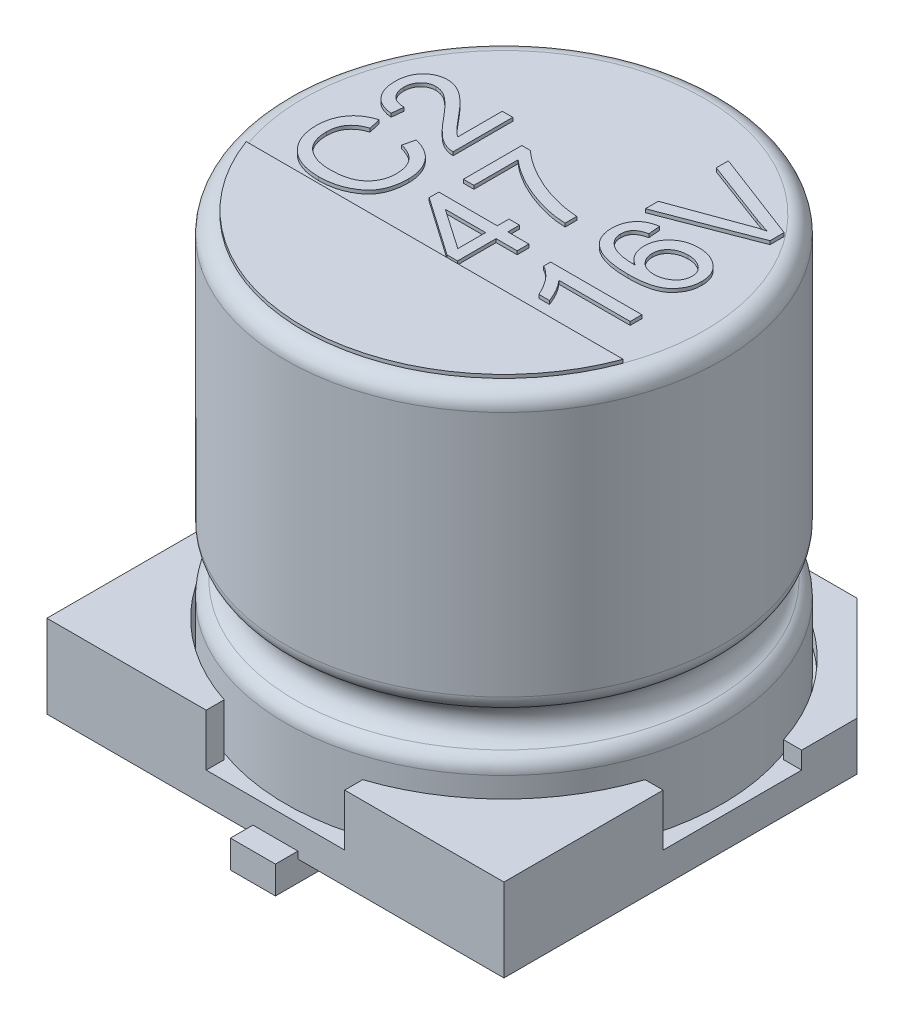
from build123d import *

# Parameters (mm, degrees)
ESQUISSE1_W               = 6.6
ESQUISSE1_H               = 6.6
BOSS_EXTRU_1_DEPTH        = 1.2
ESQUISSE2_R               = 3.2
ESQUISSE2_W               = 6.6
ESQUISSE2_H               = 2
ESQUISSE2_W_2             = 2
ESQUISSE2_H_2             = 6.6
ENL_V_MAT_EXTRU_1_DEPTH   = 0.75
ESQUISSE3_W               = 6.6
ESQUISSE3_H               = 3.3
ENL_V_MAT_EXTRU_2_DEPTH   = 0.5
CHANFREIN1_SIZE           = 1.5
ESQUISSE5_W               = 0.65
ESQUISSE5_H               = 0.65
BOSS_EXTRU_2_DEPTH        = 0.3
BOSS_EXTRU_2_DEPTH_BACK   = 0.1
BOSS_EXTRU_2_2_DEPTH      = 0.3
BOSS_EXTRU_2_2_DEPTH_BACK = 0.1
ESQUISSE6_R               = 0.5
BOSS_EXTRU_3_DEPTH        = 0.3
BOSS_EXTRU_4_DEPTH        = 0.05
BOSS_EXTRU_4_2_DEPTH      = 0.05
BOSS_EXTRU_4_3_DEPTH      = 0.05
BOSS_EXTRU_4_4_DEPTH      = 0.05
BOSS_EXTRU_4_5_DEPTH      = 0.05
BOSS_EXTRU_4_6_DEPTH      = 0.05
BOSS_EXTRU_4_7_DEPTH      = 0.05
BOSS_EXTRU_4_8_DEPTH      = 0.05


with BuildPart() as part:
    # Esquisse1 → Boss.-Extru.1 (new body)
    with BuildSketch(Plane(origin=(0, 0, 0), x_dir=(1, 0, 0), z_dir=(0, 1, 0))):
        Rectangle(ESQUISSE1_W, ESQUISSE1_H)
    extrude(amount=BOSS_EXTRU_1_DEPTH)

    # Esquisse2 → Enlèv. mat.-Extru.1 (cut)
    with BuildSketch(Plane(origin=(0, 1.2, 0), x_dir=(1, 0, 0), z_dir=(0, 1, 0))):
        Circle(ESQUISSE2_R)
        Rectangle(ESQUISSE2_W, ESQUISSE2_H)
        Rectangle(ESQUISSE2_W_2, ESQUISSE2_H_2)
    extrude(amount=-ENL_V_MAT_EXTRU_1_DEPTH, mode=Mode.SUBTRACT)

    # Esquisse3 → Enlèv. mat.-Extru.2 (cut)
    with BuildSketch(Plane(origin=(0, 1.2, 0), x_dir=(1, 0, 0), z_dir=(0, 1, 0))):
        with Locations((0, 1.65)):
            Rectangle(ESQUISSE3_W, ESQUISSE3_H)
    extrude(amount=-ENL_V_MAT_EXTRU_2_DEPTH, mode=Mode.SUBTRACT)

    # Chanfrein1
    chanfrein1_edges = [part.edges().sort_by_distance(p)[0] for p in [
        (3.3, 0.35, -3.3),
        (-3.3, 0.35, -3.3),
    ]]
    chamfer(chanfrein1_edges, length=CHANFREIN1_SIZE)

    # Esquisse6 → Boss.-Extru.3 (add)
    with BuildSketch(Plane.XZ):
        with Locations(Location((-2, 2, 0), (0, 0, 270))):  # turned: the seam where the file's is
            Circle(ESQUISSE6_R)
        with Locations(Location((2, 2, 0), (0, 0, 270))):  # turned: the seam where the file's is
            Circle(ESQUISSE6_R)
        with Locations(Location((2, -2, 0), (0, 0, 270))):  # turned: the seam where the file's is
            Circle(ESQUISSE6_R)
        with Locations(Location((-2, -2, 0), (0, 0, 270))):  # turned: the seam where the file's is
            Circle(ESQUISSE6_R)
    extrude(amount=BOSS_EXTRU_3_DEPTH)


with BuildPart() as body_2:
    # Esquisse4 → Révolution1 (revolve)
    with BuildSketch(Plane(origin=(0, 0, 0), x_dir=(0, 0, -1), z_dir=(1, 0, 0)), mode=Mode.PRIVATE) as r_volution1_sk:
        with BuildLine():
            Line((0, 6.25), (-2.9, 6.25))
            ThreePointArc((-2.9, 6.25), (-3.076776695, 6.176776695), (-3.15, 6))
            Line((-3.15, 6), (-3.15, 2.439897949))
            ThreePointArc((-3.15, 2.439897949), (-3.113200716, 2.309339707), (-3.013636364, 2.217217063))
            ThreePointArc((-3.013636364, 2.217217063), (-2.85, 1.95), (-3.013636364, 1.682782937))
            ThreePointArc((-3.013636364, 1.682782937), (-3.113200716, 1.590660293), (-3.15, 1.460102051))
            Line((-3.15, 1.460102051), (-3.15, 0.45))
            Line((-3.15, 0.45), (0, 0.45))
            Line((0, 0.45), (0, 6.25))
        make_face()
    revolve(r_volution1_sk.sketch.rotate(Axis((0, 0.45, 0), (0, 1, 0)), 180), axis=Axis((0, 0.45, 0), (0, 1, 0)))  # turned: the seam where the file's is


with BuildPart() as body_3:
    # Esquisse5 → Boss.-Extru.2 (new body, two sides)
    with BuildSketch(Plane.XZ) as boss_extru_2_sk:
        with Locations((0, 3.3)):
            Rectangle(ESQUISSE5_W, ESQUISSE5_H)
    extrude(amount=BOSS_EXTRU_2_DEPTH)
    extrude(boss_extru_2_sk.sketch, amount=-BOSS_EXTRU_2_DEPTH_BACK)


with BuildPart() as body_4:
    # Esquisse5 → Boss.-Extru.2 2 (new body, two sides)
    with BuildSketch(Plane.XZ) as boss_extru_2_2_sk:
        with Locations((0, -3.3)):
            Rectangle(ESQUISSE5_W, ESQUISSE5_H)
    extrude(amount=BOSS_EXTRU_2_2_DEPTH)
    extrude(boss_extru_2_2_sk.sketch, amount=-BOSS_EXTRU_2_2_DEPTH_BACK)


with BuildPart() as body_5:
    # Esquisse7 → Boss.-Extru.4 (new body)
    with BuildSketch(Plane(origin=(0, 6.25, 0), x_dir=(1, 0, 0), z_dir=(0, 1, 0))):
        with BuildLine():
            Line((-2.722131518, -1), (2.722131518, -1))
            ThreePointArc((2.722131518, -1), (0, -2.9), (-2.722131518, -1))
        make_face()
    extrude(amount=BOSS_EXTRU_4_DEPTH)


with BuildPart() as body_6:
    # Esquisse7 → Boss.-Extru.4 2 (new body)
    with BuildSketch(Plane(origin=(0, 6.25, 0), x_dir=(1, 0, 0), z_dir=(0, 1, 0))):
        Polygon((0.296103896, -0.071428571), (0.296103896, -0.24025974), (0.6, -0.24025974), (0.6, -0.409090909), (0.296103896, -0.409090909), (0.296103896, -0.966233766), (0.144155844, -0.966233766), (-0.7, -0.379017857), (-0.7, -0.24025974), (0.144155844, -0.24025974), (0.144155844, -0.071428571), align=None)
        Polygon((0.144155844, -0.409090909), (-0.432508117, -0.409090909), (-0.432508117, -0.412520292), (0.144155844, -0.810064935), align=None, mode=Mode.SUBTRACT)
    extrude(amount=BOSS_EXTRU_4_2_DEPTH)


with BuildPart() as body_7:
    # Esquisse7 → Boss.-Extru.4 3 (new body)
    with BuildSketch(Plane(origin=(0, 6.25, 0), x_dir=(1, 0, 0), z_dir=(0, 1, 0))):
        with BuildLine():
            add(Edge.make_bspline(
                [(-0.561769481, 0.941558442), (-0.543990179, 0.925717685), (-0.508027109, 0.893675804), (-0.450586487, 0.848641711), (-0.3904709, 0.80453927), (-0.326676072, 0.762899908), (-0.260252054, 0.721970855), (-0.19025817, 0.683445144), (-0.117295293, 0.646115762), (-0.041643658, 0.610664543), (0.036098502, 0.578196899), (0.11472146, 0.548637502), (0.194253592, 0.523543832), (0.274149315, 0.50138235), (0.354781461, 0.483647136), (0.435863592, 0.46891175), (0.517682436, 0.458379626), (0.572543391, 0.454093271), (0.6, 0.451948052)],
                knots=[0, 0, 0, 0, 0.890443169, 1.8011434, 2.72871408, 3.67830878, 4.649628621, 5.64630914, 6.665648346, 7.714738694, 8.77023317, 9.816117091, 10.855215011, 11.888472104, 12.916223604, 13.941999776, 14.970019627, 16, 16, 16, 16], degree=3))
            Line((0.6, 0.451948052), (0.6, 0.283116883))
            add(Edge.make_bspline(
                [(0.6, 0.283116883), (0.577563575, 0.284043261), (0.531991638, 0.285924881), (0.462851153, 0.292875252), (0.392095355, 0.303794478), (0.319788097, 0.318428905), (0.245841613, 0.336366822), (0.170220452, 0.35803723), (0.093079903, 0.383812161), (0.014824341, 0.412421512), (-0.06269314, 0.44439909), (-0.138070487, 0.478962459), (-0.210847697, 0.515514293), (-0.280520376, 0.554995133), (-0.34760432, 0.59655633), (-0.411639883, 0.640745749), (-0.473239776, 0.686727654), (-0.51191236, 0.719836812), (-0.531168831, 0.736323052)],
                knots=[0, 0, 0, 0, 0.869045849, 1.765169938, 2.687948117, 3.639137891, 4.619848113, 5.632498604, 6.682982998, 7.767344363, 8.85702895, 9.927714978, 10.976477627, 12.008263417, 13.026390201, 14.029951021, 15.01904175, 16, 16, 16, 16], degree=3))
            Line((-0.531168831, 0.736323052), (-0.531168831, 0.097402597))
            Line((-0.531168831, 0.097402597), (-0.683116883, 0.097402597))
            Line((-0.683116883, 0.097402597), (-0.683116883, 0.941558442))
            Line((-0.683116883, 0.941558442), (-0.561769481, 0.941558442))
        make_face()
    extrude(amount=BOSS_EXTRU_4_3_DEPTH)


with BuildPart() as body_8:
    # Esquisse7 → Boss.-Extru.4 4 (new body)
    with BuildSketch(Plane(origin=(0, 6.25, 0), x_dir=(1, 0, 0), z_dir=(0, 1, 0))):
        with BuildLine():
            Line((2.3, -0.307792208), (2.3, -0.476623377))
            Line((2.3, -0.476623377), (1.27012987, -0.476623377))
            add(Edge.make_bspline(
                [(1.27012987, -0.476623377), (1.279223462, -0.486984406), (1.297670325, -0.508002338), (1.323418107, -0.541939461), (1.348324339, -0.578158837), (1.372037178, -0.617024985), (1.39472956, -0.658496452), (1.416257396, -0.702559652), (1.436916947, -0.748996188), (1.449463122, -0.781083079), (1.455844156, -0.797402597)],
                knots=[0, 0, 0, 0, 0.887204464, 1.799744156, 2.740245044, 3.715929421, 4.729246756, 5.78238396, 6.872111789, 8, 8, 8, 8], degree=3))
            Line((1.455844156, -0.797402597), (1.303896104, -0.797402597))
            add(Edge.make_bspline(
                [(1.303896104, -0.797402597), (1.293102344, -0.774483614), (1.272072929, -0.729830701), (1.236626461, -0.66705158), (1.199399203, -0.609831301), (1.16045468, -0.558087831), (1.119141498, -0.512270563), (1.076102522, -0.471980489), (1.031133268, -0.437074324), (0.998988334, -0.418340614), (0.983116883, -0.409090909)],
                knots=[0, 0, 0, 0, 1.186218497, 2.3111021, 3.37345738, 4.381680583, 5.341076965, 6.258983301, 7.14037897, 8, 8, 8, 8], degree=3))
            Line((0.983116883, -0.409090909), (0.983116883, -0.307792208))
            Line((0.983116883, -0.307792208), (2.3, -0.307792208))
        make_face()
    extrude(amount=BOSS_EXTRU_4_4_DEPTH)


with BuildPart() as body_9:
    # Esquisse7 → Boss.-Extru.4 5 (new body)
    with BuildSketch(Plane(origin=(0, 6.25, 0), x_dir=(1, 0, 0), z_dir=(0, 1, 0))):
        with BuildLine():
            add(Edge.make_bspline(
                [(1.627049513, 0.266233766), (1.613450204, 0.275238165), (1.586906324, 0.292813447), (1.551847818, 0.323932831), (1.52224805, 0.358062815), (1.497757448, 0.394853213), (1.478733011, 0.434622693), (1.465738061, 0.47733157), (1.457178022, 0.522656734), (1.456294986, 0.5539099), (1.455844156, 0.569866071)],
                knots=[0, 0, 0, 0, 1.069954415, 2.088395883, 3.066632478, 4.029065089, 4.982046927, 5.949919737, 6.953340264, 8, 8, 8, 8], degree=3))
            add(Edge.make_bspline(
                [(1.455844156, 0.569866071), (1.456191805, 0.582548179), (1.456878439, 0.607596362), (1.462545816, 0.64439928), (1.471850024, 0.679631672), (1.484485531, 0.713546338), (1.501385133, 0.7457272), (1.521383712, 0.776893214), (1.545647627, 0.806087597), (1.57293232, 0.833726618), (1.603149516, 0.858887064), (1.63558394, 0.88126992), (1.670435777, 0.899630894), (1.70699582, 0.915123616), (1.745722852, 0.927004517), (1.786547903, 0.935275404), (1.829318218, 0.940838077), (1.858558723, 0.941315506), (1.8734375, 0.941558442)],
                knots=[0, 0, 0, 0, 0.975125205, 1.925950693, 2.856152245, 3.774449697, 4.70315003, 5.646803566, 6.617626571, 7.617215937, 8.630442275, 9.637872749, 10.642483832, 11.65496491, 12.688309326, 13.752171127, 14.856211817, 16, 16, 16, 16], degree=3))
            add(Edge.make_bspline(
                [(1.8734375, 0.941558442), (1.888580343, 0.941317494), (1.918347182, 0.940843855), (1.961983437, 0.935238168), (2.004065218, 0.926985596), (2.04426656, 0.91475994), (2.082960891, 0.899469991), (2.119576045, 0.880323032), (2.154744008, 0.858075663), (2.187621145, 0.832380443), (2.218017881, 0.804115367), (2.244524958, 0.773169631), (2.26683893, 0.739924589), (2.285202716, 0.704550145), (2.299579764, 0.666870265), (2.309430036, 0.626812278), (2.315698497, 0.584571905), (2.316482257, 0.55564374), (2.316883117, 0.540848214)],
                knots=[0, 0, 0, 0, 1.085548404, 2.133902048, 3.150719742, 4.158438961, 5.143478499, 6.130857801, 7.117733313, 8.124563847, 9.119649328, 10.090449915, 11.040371519, 11.985443394, 12.943683995, 13.925811242, 14.939140701, 16, 16, 16, 16], degree=3))
            add(Edge.make_bspline(
                [(2.316883117, 0.540848214), (2.316485003, 0.525789733), (2.315699126, 0.496064278), (2.30922735, 0.45227623), (2.298467941, 0.410260062), (2.283175096, 0.369999989), (2.263930883, 0.331398768), (2.240229667, 0.294431855), (2.212090634, 0.25937232), (2.185526962, 0.231697854), (2.16173043, 0.210909807), (2.141984459, 0.196313685), (2.12071524, 0.182321071), (2.097548676, 0.169925454), (2.072879154, 0.158124335), (2.046428775, 0.147771295), (2.018546469, 0.137838126), (1.988771702, 0.129565645), (1.957480451, 0.121857064), (1.924464164, 0.115322522), (1.889799343, 0.10974132), (1.853435335, 0.105427189), (1.815463748, 0.101534382), (1.775761166, 0.099407309), (1.734430917, 0.09766443), (1.70627918, 0.09749094), (1.691943994, 0.097402597)],
                knots=[0, 0, 0, 0, 1.247779403, 2.463117631, 3.659976664, 4.836419457, 6.026221779, 7.229279442, 8.468942427, 9.747322861, 10.403533791, 11.085784176, 11.78126166, 12.511907243, 13.26182283, 14.046870347, 14.865219006, 15.714252586, 16.607026578, 17.536193268, 18.503241106, 19.516724355, 20.571286828, 21.666600567, 22.811806305, 24, 24, 24, 24], degree=3))
            add(Edge.make_bspline(
                [(1.691943994, 0.097402597), (1.66405944, 0.097732004), (1.610078492, 0.098369693), (1.53179155, 0.103971256), (1.45884114, 0.113044828), (1.391205321, 0.125820084), (1.328908012, 0.142369357), (1.271919877, 0.16260206), (1.220163171, 0.186578768), (1.173754642, 0.214256842), (1.132735067, 0.245565842), (1.097145189, 0.280237509), (1.066919268, 0.318271077), (1.042563218, 0.359827163), (1.02338332, 0.404577389), (1.009730122, 0.452607049), (1.001342979, 0.503973819), (1.000455589, 0.53932045), (1, 0.557467532)],
                knots=[0, 0, 0, 0, 1.424582619, 2.757810733, 4.007769843, 5.178820556, 6.271924257, 7.297969076, 8.264779121, 9.181696118, 10.053356541, 10.895296698, 11.714155951, 12.52784682, 13.349044585, 14.195146158, 15.073381762, 16, 16, 16, 16], degree=3))
            add(Edge.make_bspline(
                [(1, 0.557467532), (1.000266189, 0.569347725), (1.000788053, 0.592638937), (1.004513002, 0.626879674), (1.010823326, 0.659713581), (1.019796421, 0.691242231), (1.031438305, 0.721314076), (1.045468679, 0.750058478), (1.062151749, 0.777202626), (1.081137312, 0.802951217), (1.10276139, 0.826674161), (1.1269229, 0.848246212), (1.153717516, 0.867207906), (1.182816476, 0.883930992), (1.2145108, 0.897931697), (1.248615786, 0.909424797), (1.285095392, 0.918837371), (1.310447816, 0.922699565), (1.323417208, 0.924675325)],
                knots=[0, 0, 0, 0, 1.05367056, 2.065729412, 3.050830916, 4.016126385, 4.969213069, 5.907536784, 6.849258065, 7.791463712, 8.741097404, 9.691307467, 10.658743283, 11.647450802, 12.663499054, 13.726567437, 14.836993312, 16, 16, 16, 16], degree=3))
            Line((1.323417208, 0.924675325), (1.337662338, 0.755844156))
            add(Edge.make_bspline(
                [(1.337662338, 0.755844156), (1.321728395, 0.75208586), (1.291447841, 0.744943667), (1.249723652, 0.728902171), (1.214342308, 0.708544848), (1.185174599, 0.684021814), (1.162541528, 0.655279008), (1.14637255, 0.622526032), (1.136698364, 0.585712537), (1.135622605, 0.559813809), (1.135064935, 0.546387987)],
                knots=[0, 0, 0, 0, 1.226492651, 2.330802743, 3.33829511, 4.273637758, 5.170477757, 6.060897429, 6.994775133, 8, 8, 8, 8], degree=3))
            add(Edge.make_bspline(
                [(1.135064935, 0.546387987), (1.135418359, 0.536865112), (1.13612146, 0.517920305), (1.141813944, 0.490115874), (1.15120395, 0.463353983), (1.164247094, 0.437644759), (1.181017926, 0.412855033), (1.201917031, 0.389479109), (1.225918202, 0.366662204), (1.253763855, 0.345234113), (1.285645474, 0.325567517), (1.321890842, 0.308436717), (1.362583263, 0.294435138), (1.40723256, 0.282445887), (1.456249779, 0.27378698), (1.509334201, 0.26718345), (1.566755969, 0.26323262), (1.606466954, 0.262776826), (1.627049513, 0.262540584)],
                knots=[0, 0, 0, 0, 0.724409215, 1.441139678, 2.150297782, 2.877700373, 3.629574527, 4.421695389, 5.259767472, 6.14740045, 7.091057935, 8.106037173, 9.192047824, 10.362655148, 11.621681866, 12.977431459, 14.433375649, 16, 16, 16, 16], degree=3))
            Line((1.627049513, 0.262540584), (1.627049513, 0.266233766))
        make_face()
        with BuildLine():
            add(Edge.make_bspline(
                [(2.181818182, 0.536099838), (2.181568318, 0.544730718), (2.181078587, 0.561647203), (2.177124181, 0.586405497), (2.170111881, 0.609693653), (2.160894294, 0.631944567), (2.148641556, 0.652804154), (2.133757323, 0.672448191), (2.116205223, 0.690740401), (2.096179435, 0.707446087), (2.074354581, 0.722675103), (2.051171698, 0.736142616), (2.02680406, 0.74752572), (2.001378748, 0.756771669), (1.974821002, 0.763969329), (1.947084994, 0.768811814), (1.918276627, 0.77216642), (1.898684144, 0.772538422), (1.888737825, 0.772727273)],
                knots=[0, 0, 0, 0, 0.985621802, 1.931814126, 2.853484768, 3.758252722, 4.676468835, 5.608588604, 6.5676484, 7.56562942, 8.582686171, 9.604295749, 10.624324039, 11.65066286, 12.691060434, 13.762839569, 14.864283136, 16, 16, 16, 16], degree=3))
            add(Edge.make_bspline(
                [(1.888737825, 0.772727273), (1.878791822, 0.772538292), (1.859287392, 0.772167695), (1.830818773, 0.76886745), (1.803625762, 0.763924886), (1.77774465, 0.75681719), (1.753100396, 0.747564027), (1.729761047, 0.73619713), (1.707854683, 0.722641789), (1.687250682, 0.70743414), (1.668584593, 0.690451128), (1.652408352, 0.671792765), (1.638410137, 0.651947387), (1.627512427, 0.63030834), (1.618191522, 0.60759186), (1.612402747, 0.583107837), (1.608551277, 0.55741421), (1.608048678, 0.539808054), (1.607792208, 0.530823864)],
                knots=[0, 0, 0, 0, 1.146383952, 2.248095505, 3.300025281, 4.330631945, 5.338088421, 6.331106039, 7.318778256, 8.304262475, 9.280208679, 10.221574778, 11.146861143, 12.071925297, 13.009516616, 13.970978403, 14.964616916, 16, 16, 16, 16], degree=3))
            add(Edge.make_bspline(
                [(1.607792208, 0.530823864), (1.607939363, 0.522541124), (1.608230522, 0.506152986), (1.612236929, 0.482077137), (1.617844731, 0.458763298), (1.626262155, 0.436375771), (1.636613389, 0.414751193), (1.649943308, 0.394347961), (1.664828806, 0.374353159), (1.682526243, 0.355882187), (1.701818666, 0.338759636), (1.722905284, 0.323875968), (1.745387123, 0.311119324), (1.769547778, 0.300788247), (1.795238644, 0.292988165), (1.822303769, 0.287105465), (1.850836163, 0.283644735), (1.870350413, 0.283295088), (1.880296266, 0.283116883)],
                knots=[0, 0, 0, 0, 0.964721787, 1.908788045, 2.83888565, 3.756980023, 4.692487839, 5.628332754, 6.594252615, 7.595238226, 8.60516442, 9.598082325, 10.599015417, 11.614185319, 12.655278625, 13.72520881, 14.840604126, 16, 16, 16, 16], degree=3))
            add(Edge.make_bspline(
                [(1.880296266, 0.283116883), (1.890507691, 0.283286935), (1.910638719, 0.283622179), (1.940255727, 0.287255443), (1.968804316, 0.292626469), (1.99617096, 0.300626163), (2.022286204, 0.310915399), (2.047226077, 0.323430039), (2.071143302, 0.337956198), (2.093546616, 0.354775367), (2.114389341, 0.37294797), (2.132380715, 0.392825333), (2.147634985, 0.413865872), (2.160026551, 0.436123402), (2.169953686, 0.459427418), (2.176741364, 0.484003962), (2.181161479, 0.50964767), (2.181597232, 0.527199926), (2.181818182, 0.536099838)],
                knots=[0, 0, 0, 0, 1.117888879, 2.203830858, 3.263487087, 4.296727522, 5.321539455, 6.333737417, 7.349594489, 8.38207154, 9.398658853, 10.373700902, 11.311944705, 12.238999299, 13.158417895, 14.079197511, 15.026052622, 16, 16, 16, 16], degree=3))
        make_face(mode=Mode.SUBTRACT)
    extrude(amount=BOSS_EXTRU_4_5_DEPTH)


with BuildPart() as body_10:
    # Esquisse7 → Boss.-Extru.4 6 (new body)
    with BuildSketch(Plane(origin=(0, 6.25, 0), x_dir=(1, 0, 0), z_dir=(0, 1, 0))):
        with BuildLine():
            Line((1, 2.241558442), (2.3, 1.746672078))
            Line((2.3, 1.746672078), (2.3, 1.543019481))
            Line((2.3, 1.543019481), (1, 1.042857143))
            Line((1, 1.042857143), (1, 1.229362825))
            Line((1, 1.229362825), (1.943871753, 1.57362013))
            add(Edge.make_bspline(
                [(1.943871753, 1.57362013), (1.959566765, 1.579978572), (1.991939898, 1.593093737), (2.042890769, 1.611101638), (2.097947882, 1.62727369), (2.136063931, 1.637129747), (2.15570211, 1.642207792)],
                knots=[0, 0, 0, 0, 0.91165355, 1.880411525, 2.907944069, 4, 4, 4, 4], degree=3))
            Line((2.15570211, 1.642207792), (2.15570211, 1.645637175))
            add(Edge.make_bspline(
                [(2.15570211, 1.645637175), (2.120645079, 1.6552872), (2.049106452, 1.674979383), (1.979412596, 1.700446379), (1.943871753, 1.713433442)],
                knots=[0, 0, 0, 0, 0.980086758, 2, 2, 2, 2], degree=3))
            Line((1.943871753, 1.713433442), (1, 2.066396104))
            Line((1, 2.066396104), (1, 2.241558442))
        make_face()
    extrude(amount=BOSS_EXTRU_4_6_DEPTH)


with BuildPart() as body_11:
    # Esquisse7 → Boss.-Extru.4 7 (new body)
    with BuildSketch(Plane(origin=(0, 6.25, 0), x_dir=(1, 0, 0), z_dir=(0, 1, 0))):
        with BuildLine():
            add(Edge.make_bspline(
                [(-1.513592158, 0.249350649), (-1.4960214, 0.244303324), (-1.461759042, 0.234461218), (-1.412593327, 0.216155806), (-1.366938399, 0.19504078), (-1.324459979, 0.171453639), (-1.285908441, 0.144477896), (-1.250196964, 0.115632483), (-1.218483013, 0.083363689), (-1.18996861, 0.048846903), (-1.16487982, 0.012071485), (-1.143128862, -0.02657473), (-1.124942499, -0.067156877), (-1.109834773, -0.109380334), (-1.098268561, -0.153446835), (-1.089806823, -0.199192919), (-1.084682238, -0.246825133), (-1.08413979, -0.27920129), (-1.083864074, -0.295657468)],
                knots=[0, 0, 0, 0, 1.162857345, 2.267530702, 3.333896634, 4.360953501, 5.354188413, 6.324128997, 7.277551337, 8.227421396, 9.16936615, 10.106212879, 11.045228817, 11.99549423, 12.956291262, 13.940599034, 14.953246115, 16, 16, 16, 16], degree=3))
            add(Edge.make_bspline(
                [(-1.083864074, -0.295657468), (-1.084002268, -0.308939973), (-1.084274308, -0.335087004), (-1.086826309, -0.373528498), (-1.090264986, -0.410634922), (-1.096031592, -0.446228894), (-1.102637871, -0.480658158), (-1.111543704, -0.513589996), (-1.121390452, -0.545291267), (-1.133094184, -0.575484226), (-1.146254947, -0.604322156), (-1.161119728, -0.631722116), (-1.177140695, -0.658072753), (-1.195130913, -0.682711381), (-1.214446076, -0.706210022), (-1.235631759, -0.727957902), (-1.258079516, -0.748690809), (-1.290094437, -0.774217219), (-1.332659216, -0.802741768), (-1.386125027, -0.833064835), (-1.442164038, -0.858676189), (-1.500751997, -0.879635561), (-1.561953727, -0.895646543), (-1.625610685, -0.90724736), (-1.691765608, -0.914197528), (-1.736661347, -0.91511743), (-1.759452548, -0.915584416)],
                knots=[0, 0, 0, 0, 0.919048861, 1.809176737, 2.665355953, 3.496739813, 4.303484252, 5.090196945, 5.856160975, 6.599753386, 7.329497334, 8.048274368, 8.75588838, 9.461878281, 10.1576449, 10.859135909, 11.561154594, 12.271067417, 13.690501802, 15.101956996, 16.520647685, 17.948820654, 19.402690566, 20.893468995, 22.422977939, 24, 24, 24, 24], degree=3))
            add(Edge.make_bspline(
                [(-1.759452548, -0.915584416), (-1.784537126, -0.915126183), (-1.833440067, -0.91423285), (-1.90466678, -0.905892563), (-1.971729467, -0.892348942), (-2.034528653, -0.873014532), (-2.093257336, -0.848521581), (-2.147723222, -0.818204154), (-2.198036061, -0.782539237), (-2.243743536, -0.741513044), (-2.284344718, -0.696165733), (-2.320468185, -0.64779865), (-2.350184818, -0.595702833), (-2.374914779, -0.540782598), (-2.394262083, -0.482729019), (-2.407841323, -0.421561732), (-2.416272222, -0.357270765), (-2.41717088, -0.313358613), (-2.417630307, -0.290909091)],
                knots=[0, 0, 0, 0, 1.17572582, 2.292103567, 3.356980097, 4.379388748, 5.367919477, 6.334990253, 7.295924977, 8.253572839, 9.20815403, 10.145711904, 11.078462153, 12.014059973, 12.965796811, 13.941999351, 14.947873673, 16, 16, 16, 16], degree=3))
            add(Edge.make_bspline(
                [(-2.417630307, -0.290909091), (-2.41731238, -0.275071277), (-2.416687586, -0.243946738), (-2.412170958, -0.198086096), (-2.40449008, -0.154027319), (-2.394060115, -0.111624336), (-2.380156591, -0.071126775), (-2.363672815, -0.032181121), (-2.343631931, 0.004814832), (-2.321174134, 0.040292183), (-2.295123554, 0.073195167), (-2.266638951, 0.104011973), (-2.235069724, 0.132061229), (-2.200668282, 0.157399044), (-2.163472827, 0.180170198), (-2.123544472, 0.200502773), (-2.080766535, 0.218263422), (-2.050853453, 0.227680961), (-2.035649788, 0.232467532)],
                knots=[0, 0, 0, 0, 1.084719424, 2.13169519, 3.152567876, 4.145885688, 5.119153041, 6.082398705, 7.038974436, 7.997955175, 8.954606747, 9.909189511, 10.869020972, 11.84234423, 12.831930089, 13.852802775, 14.90866256, 16, 16, 16, 16], degree=3))
            Line((-2.035649788, 0.232467532), (-1.995552385, 0.063636364))
            add(Edge.make_bspline(
                [(-1.995552385, 0.063636364), (-2.006509836, 0.059820642), (-2.027883688, 0.052377608), (-2.058458961, 0.039040776), (-2.086922234, 0.0243156), (-2.113384187, 0.00820755), (-2.137828041, -0.009214092), (-2.160090295, -0.028267501), (-2.180155654, -0.048895982), (-2.198164528, -0.070865341), (-2.214166073, -0.094199264), (-2.227765961, -0.11913751), (-2.239811836, -0.145210726), (-2.249219317, -0.172832666), (-2.256672967, -0.201754028), (-2.261853498, -0.232107359), (-2.265115879, -0.263930132), (-2.265490695, -0.285624931), (-2.265682255, -0.296712662)],
                knots=[0, 0, 0, 0, 1.144066344, 2.231641889, 3.286745147, 4.302659249, 5.284651632, 6.244173363, 7.188683126, 8.119273077, 9.043007686, 9.974688197, 10.917843137, 11.872334576, 12.848372524, 13.860726428, 14.906664664, 16, 16, 16, 16], degree=3))
            add(Edge.make_bspline(
                [(-2.265682255, -0.296712662), (-2.265291886, -0.314581072), (-2.264531624, -0.349380693), (-2.258212981, -0.399946073), (-2.247375311, -0.447218149), (-2.232403077, -0.491236313), (-2.213072642, -0.531910595), (-2.189452791, -0.569149539), (-2.161446067, -0.602997999), (-2.1292281, -0.633328742), (-2.093180065, -0.659774043), (-2.054411938, -0.6832659), (-2.012662334, -0.702963581), (-1.967997746, -0.719202237), (-1.920341378, -0.731425176), (-1.86991137, -0.740390219), (-1.816546291, -0.745693444), (-1.780040899, -0.746393725), (-1.761299139, -0.746753247)],
                knots=[0, 0, 0, 0, 1.116887436, 2.175194062, 3.179398072, 4.144308485, 5.07628433, 5.988313003, 6.89424019, 7.815960346, 8.747271137, 9.684453683, 10.645975242, 11.62857767, 12.651331023, 13.717887571, 14.828370253, 16, 16, 16, 16], degree=3))
            add(Edge.make_bspline(
                [(-1.761299139, -0.746753247), (-1.739831712, -0.746415862), (-1.698227937, -0.745762012), (-1.637906274, -0.740252372), (-1.581804132, -0.73084142), (-1.530004561, -0.717697653), (-1.482339102, -0.701200524), (-1.438999096, -0.680598272), (-1.400053347, -0.655924078), (-1.365220913, -0.627888023), (-1.334983422, -0.596559679), (-1.308321773, -0.563173913), (-1.285718371, -0.527400303), (-1.267495082, -0.489093484), (-1.253152604, -0.44861818), (-1.243234477, -0.4057833), (-1.237019922, -0.360822054), (-1.236219781, -0.330059885), (-1.235812126, -0.314387175)],
                knots=[0, 0, 0, 0, 1.335001587, 2.587227048, 3.763267398, 4.869534239, 5.907361014, 6.89562929, 7.846964169, 8.768579182, 9.669714952, 10.54947023, 11.421953692, 12.295242416, 13.182597618, 14.087311047, 15.025523218, 16, 16, 16, 16], degree=3))
            add(Edge.make_bspline(
                [(-1.235812126, -0.314387175), (-1.236077835, -0.301540465), (-1.236597646, -0.276408303), (-1.240305017, -0.239535139), (-1.246591455, -0.204523337), (-1.255320311, -0.171350975), (-1.266353179, -0.140033512), (-1.280111907, -0.110591408), (-1.296574594, -0.083102075), (-1.315352098, -0.057295319), (-1.336849781, -0.033538991), (-1.360703344, -0.011575616), (-1.387011767, 0.008693618), (-1.416103094, 0.026748256), (-1.447591775, 0.043138752), (-1.481546005, 0.057655194), (-1.518028854, 0.070397132), (-1.543525492, 0.077089797), (-1.556591346, 0.080519481)],
                knots=[0, 0, 0, 0, 1.107397515, 2.166413932, 3.190899866, 4.170923074, 5.120390243, 6.049577835, 6.967409733, 7.878644088, 8.796507289, 9.724581045, 10.670683286, 11.655006723, 12.672174807, 13.728257053, 14.83583617, 16, 16, 16, 16], degree=3))
            Line((-1.556591346, 0.080519481), (-1.513592158, 0.249350649))
        make_face()
    extrude(amount=BOSS_EXTRU_4_7_DEPTH)


with BuildPart() as body_12:
    # Esquisse7 → Boss.-Extru.4 8 (new body)
    with BuildSketch(Plane(origin=(0, 6.25, 0), x_dir=(1, 0, 0), z_dir=(0, 1, 0))):
        with BuildLine():
            Line((-1.10074719, 1.228571429), (-1.10074719, 0.367532468))
            add(Edge.make_bspline(
                [(-1.10074719, 0.367532468), (-1.109812552, 0.367838169), (-1.128091673, 0.368454576), (-1.155581711, 0.37185773), (-1.183081129, 0.37804178), (-1.210668211, 0.386563068), (-1.238345997, 0.397413354), (-1.266193806, 0.410589569), (-1.293797307, 0.426686967), (-1.322257829, 0.444670471), (-1.35132615, 0.466494883), (-1.381797095, 0.492211734), (-1.41441685, 0.521719194), (-1.448186622, 0.556055866), (-1.484534211, 0.593882738), (-1.522000541, 0.636445856), (-1.561429065, 0.683020947), (-1.587955213, 0.715697204), (-1.601700924, 0.73262987)],
                knots=[0, 0, 0, 0, 0.6796431, 1.370411742, 2.07240806, 2.789555471, 3.532466849, 4.298947543, 5.095988285, 5.92599991, 6.82102785, 7.817621663, 8.914000656, 10.116368331, 11.426330088, 12.845554693, 14.365382899, 16, 16, 16, 16], degree=3))
            add(Edge.make_bspline(
                [(-1.601700924, 0.73262987), (-1.61887004, 0.753598853), (-1.652805771, 0.795045236), (-1.705675797, 0.854127484), (-1.760121904, 0.909080462), (-1.805978602, 0.95232677), (-1.843437043, 0.983677458), (-1.871309875, 1.004259596), (-1.899690996, 1.020978816), (-1.92773426, 1.035326567), (-1.956096421, 1.046041229), (-1.984359497, 1.054199706), (-2.01281693, 1.058724131), (-2.031766425, 1.059402783), (-2.041189561, 1.05974026)],
                knots=[0, 0, 0, 0, 1.727365886, 3.414236585, 5.051125997, 6.657366303, 7.42955054, 8.163886393, 8.862711004, 9.526964272, 10.169215867, 10.792073404, 11.3993267, 12, 12, 12, 12], degree=3))
            add(Edge.make_bspline(
                [(-2.041189561, 1.05974026), (-2.049115926, 1.059550364), (-2.06468221, 1.059177434), (-2.087547396, 1.055848481), (-2.109484946, 1.050795356), (-2.130121695, 1.042877612), (-2.149938766, 1.033511581), (-2.168327225, 1.021333672), (-2.186234903, 1.007779357), (-2.202378892, 0.991616094), (-2.217108647, 0.974034246), (-2.230074735, 0.955213877), (-2.24131492, 0.935346364), (-2.250260494, 0.914172562), (-2.257067531, 0.891866084), (-2.262149738, 0.868589348), (-2.265038382, 0.844113437), (-2.265464318, 0.827428943), (-2.265682255, 0.818892045)],
                knots=[0, 0, 0, 0, 1.031811344, 2.026334621, 3.004164389, 3.957265922, 4.899779801, 5.852881334, 6.82425049, 7.820421148, 8.820534449, 9.808573505, 10.793087995, 11.78866591, 12.795771953, 13.826883829, 14.888089174, 16, 16, 16, 16], degree=3))
            add(Edge.make_bspline(
                [(-2.265682255, 0.818892045), (-2.265465708, 0.810267015), (-2.2650424, 0.793406808), (-2.262122813, 0.768586833), (-2.257069858, 0.744868134), (-2.250259983, 0.722038675), (-2.241326559, 0.700335524), (-2.230019046, 0.679893056), (-2.217100247, 0.660362917), (-2.20247601, 0.641799628), (-2.185520917, 0.625183978), (-2.166622413, 0.610503583), (-2.14571863, 0.598085773), (-2.122741657, 0.588024146), (-2.097873515, 0.580186132), (-2.071133768, 0.57435252), (-2.042418886, 0.570956109), (-2.022644748, 0.570411202), (-2.012435502, 0.57012987)],
                knots=[0, 0, 0, 0, 1.031812441, 2.01698662, 2.984649478, 3.929806142, 4.863654442, 5.786355652, 6.720026173, 7.663072848, 8.607819605, 9.552624931, 10.519658563, 11.508756638, 12.546771345, 13.634199285, 14.778553981, 16, 16, 16, 16], degree=3))
            Line((-2.012435502, 0.57012987), (-2.030637613, 0.401298701))
            add(Edge.make_bspline(
                [(-2.030637613, 0.401298701), (-2.045181325, 0.402811718), (-2.073659774, 0.405774399), (-2.11481109, 0.414257583), (-2.153413885, 0.425886911), (-2.189279899, 0.440644489), (-2.222705511, 0.458316295), (-2.253066349, 0.479719551), (-2.281280934, 0.503642785), (-2.306322602, 0.530991206), (-2.328379882, 0.560827374), (-2.347748358, 0.592602421), (-2.364122012, 0.626266882), (-2.377731504, 0.661790572), (-2.387888994, 0.699389244), (-2.395244174, 0.73881804), (-2.399835034, 0.780181864), (-2.400438635, 0.80841597), (-2.40074719, 0.822849026)],
                knots=[0, 0, 0, 0, 1.121289774, 2.195628777, 3.217890541, 4.210126713, 5.166915201, 6.112001681, 7.054484082, 7.999787246, 8.949677246, 9.897264597, 10.850693622, 11.8179611, 12.811412054, 13.834207939, 14.892863877, 16, 16, 16, 16], degree=3))
            add(Edge.make_bspline(
                [(-2.40074719, 0.822849026), (-2.400491832, 0.838429256), (-2.399995558, 0.86870841), (-2.394749613, 0.912798703), (-2.386799133, 0.954350542), (-2.375145076, 0.993204355), (-2.360409218, 1.029460084), (-2.341962652, 1.062850748), (-2.320709265, 1.093969802), (-2.295745952, 1.121804886), (-2.268636884, 1.146671142), (-2.240249757, 1.168835227), (-2.210035053, 1.186960259), (-2.178926949, 1.202646735), (-2.14601932, 1.214015323), (-2.111988856, 1.222641851), (-2.076517549, 1.22773876), (-2.0523732, 1.228291329), (-2.040134366, 1.228571429)],
                knots=[0, 0, 0, 0, 1.226374278, 2.383378012, 3.491544918, 4.554095796, 5.572566929, 6.567339196, 7.552739974, 8.533800296, 9.504097501, 10.447305466, 11.364140806, 12.27462574, 13.185742444, 14.099381857, 15.036571671, 16, 16, 16, 16], degree=3))
            add(Edge.make_bspline(
                [(-2.040134366, 1.228571429), (-2.029744501, 1.228330947), (-2.008791916, 1.227845984), (-1.977359035, 1.223437408), (-1.94577076, 1.216278849), (-1.914154165, 1.206150089), (-1.882367429, 1.193479062), (-1.850633677, 1.177836107), (-1.818988012, 1.15915491), (-1.78642361, 1.137828784), (-1.752726044, 1.111837452), (-1.716535419, 1.081037521), (-1.678284227, 1.043924132), (-1.636397158, 1.002232144), (-1.592574166, 0.954147613), (-1.545502518, 0.900932577), (-1.496102554, 0.84182761), (-1.462614012, 0.800302815), (-1.445268294, 0.778794643)],
                knots=[0, 0, 0, 0, 0.647266628, 1.305301832, 1.974044492, 2.663877698, 3.372185328, 4.105022653, 4.866383139, 5.66134239, 6.529461504, 7.516814748, 8.621586341, 9.850038094, 11.1997065, 12.675225268, 14.2779005, 16, 16, 16, 16], degree=3))
            add(Edge.make_bspline(
                [(-1.445268294, 0.778794643), (-1.436109233, 0.767389994), (-1.418439067, 0.74538752), (-1.391619775, 0.714475151), (-1.366047991, 0.686220691), (-1.341700244, 0.660598603), (-1.318071603, 0.638009837), (-1.295485977, 0.618365809), (-1.274158275, 0.601106382), (-1.259630669, 0.591567036), (-1.252695242, 0.587012987)],
                knots=[0, 0, 0, 0, 1.28638092, 2.481756772, 3.598704207, 4.637980996, 5.589780294, 6.472288135, 7.270675925, 8, 8, 8, 8], degree=3))
            Line((-1.252695242, 0.587012987), (-1.252695242, 1.228571429))
            Line((-1.252695242, 1.228571429), (-1.10074719, 1.228571429))
        make_face()
    extrude(amount=BOSS_EXTRU_4_8_DEPTH)


solid = Compound([part.part, body_2.part, body_3.part, body_4.part, body_5.part, body_6.part, body_7.part, body_8.part, body_9.part, body_10.part, body_11.part, body_12.part])
